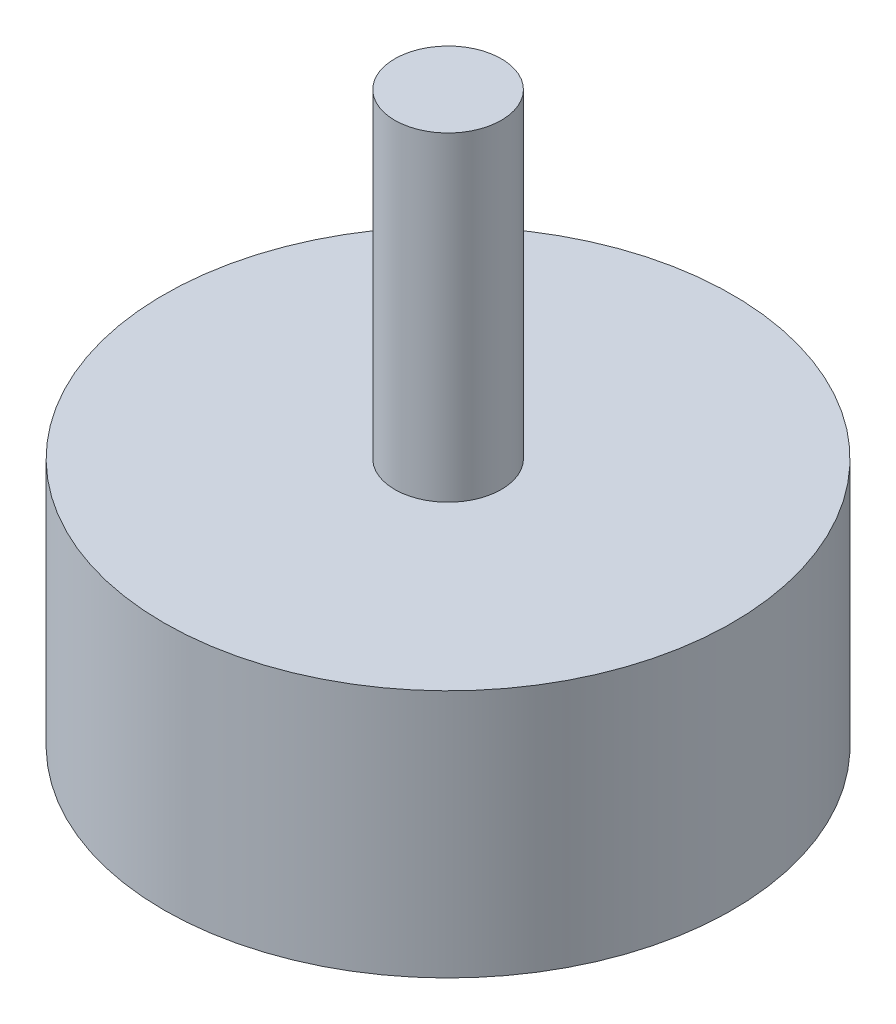
from build123d import *

# Parameters (mm, degrees)
SKETCH1_R           = 25.4
BOSS_EXTRUDE1_DEPTH = 11.1125
SKETCH2_R           = 4.7625
BOSS_EXTRUDE2_DEPTH = 28.575
SKETCH3_R           = 4.7625
CUT_EXTRUDE1_DEPTH  = 15.875


with BuildPart() as part:
    # Sketch1 → Boss-Extrude1 (new body, symmetric)
    with BuildSketch(Plane(origin=(0, 0, 0), x_dir=(1, 0, 0), z_dir=(0, 1, 0))):
        Circle(SKETCH1_R)
    extrude(amount=BOSS_EXTRUDE1_DEPTH, both=True)

    # Sketch2 → Boss-Extrude2 (add)
    with BuildSketch(Plane(origin=(0, 11.1125, 0), x_dir=(1, 0, 0), z_dir=(0, 1, 0))):
        Circle(SKETCH2_R)
    boss_extrude2 = extrude(amount=BOSS_EXTRUDE2_DEPTH)

    # Mirror1: Boss-Extrude2 across plane
    add(boss_extrude2.mirror(Plane.ZX))

    # Sketch3 → Cut-Extrude1 (cut)
    with BuildSketch(Plane(origin=(0, -39.6875, 0), x_dir=(-1, 0, 0), z_dir=(0, -1, 0))):
        Circle(SKETCH3_R)
    extrude(amount=-CUT_EXTRUDE1_DEPTH, mode=Mode.SUBTRACT)


solid = part.part
